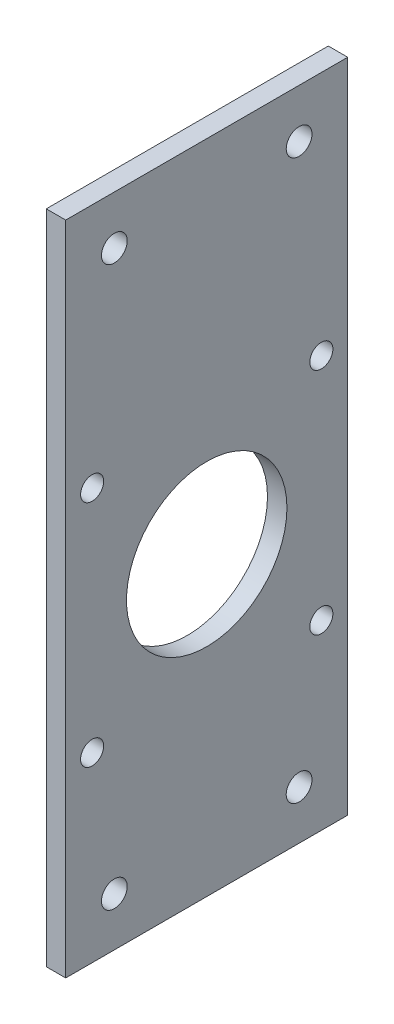
from build123d import *

# Parameters (mm, degrees)
SKETCH1_W           = 58
SKETCH1_H           = 135
SKETCH1_R           = 16.5
SKETCH1_R_2         = 2.375
SKETCH1_R_3         = 2.65
BOSS_EXTRUDE1_DEPTH = 4


with BuildPart() as part:
    # Sketch1 → Boss-Extrude1 (new body)
    with BuildSketch(Plane(origin=(0, 0, 0), x_dir=(0, 0, -1), z_dir=(1, 0, 0))):
        Rectangle(SKETCH1_W, SKETCH1_H)
        with Locations((0, -6.5)):
            Circle(SKETCH1_R, mode=Mode.SUBTRACT)
        with Locations((23.57, 17.07)):
            Circle(SKETCH1_R_2, mode=Mode.SUBTRACT)
        with Locations((-23.57, 17.07)):
            Circle(SKETCH1_R_2, mode=Mode.SUBTRACT)
        with Locations((-23.57, -30.07)):
            Circle(SKETCH1_R_2, mode=Mode.SUBTRACT)
        with Locations((23.57, -30.07)):
            Circle(SKETCH1_R_2, mode=Mode.SUBTRACT)
        with Locations((-19, 57.5)):
            Circle(SKETCH1_R_3, mode=Mode.SUBTRACT)
        with Locations((19, 57.5)):
            Circle(SKETCH1_R_3, mode=Mode.SUBTRACT)
        with Locations((-19, -57.5)):
            Circle(SKETCH1_R_3, mode=Mode.SUBTRACT)
        with Locations((19, -57.5)):
            Circle(SKETCH1_R_3, mode=Mode.SUBTRACT)
    extrude(amount=BOSS_EXTRUDE1_DEPTH)


solid = part.part
